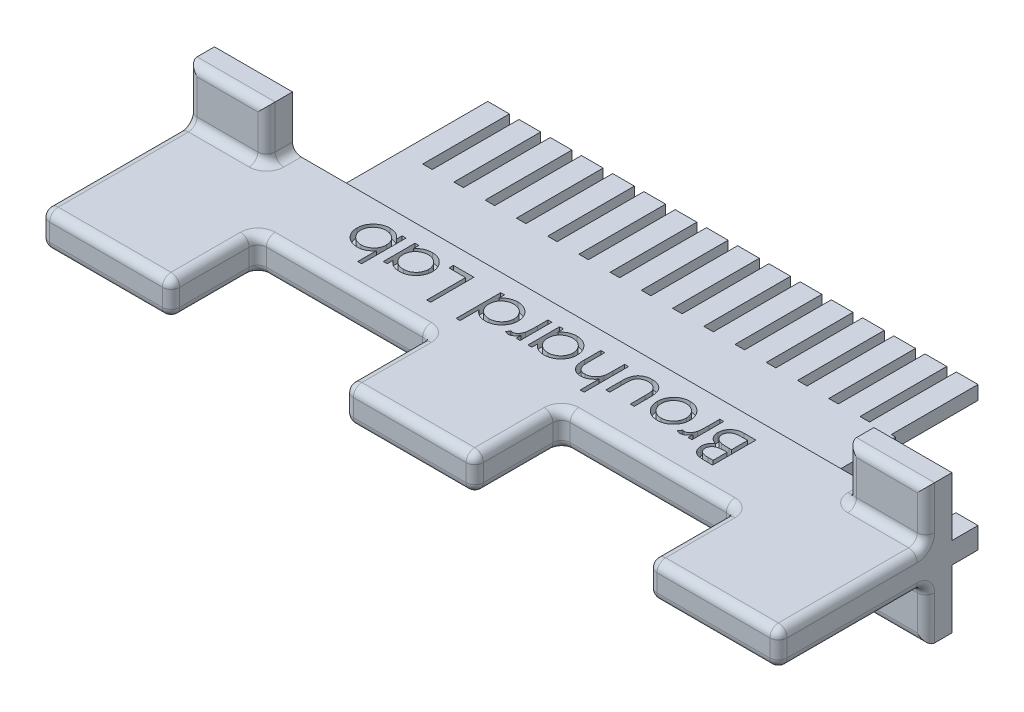
from build123d import *

# Parameters (mm, degrees)
SKETCH1_W           = 85
SKETCH1_H           = 4
BOSS_EXTRUDE1_DEPTH = 10
SKETCH2_W           = 15
SKETCH2_H           = 4
BOSS_EXTRUDE2_DEPTH = 10
SKETCH3_W           = 2.55
SKETCH3_H           = 2.45
BOSS_EXTRUDE3_DEPTH = 3
SKETCH4_W           = 57
SKETCH4_H           = 1.6
BOSS_EXTRUDE4_DEPTH = 7.5
SKETCH6_W           = 9
SKETCH6_H           = 6
BOSS_EXTRUDE6_DEPTH = 3
FILLET1_R           = 1
CUT_EXTRUDE1_DEPTH  = 1
SKETCH5_W           = 2.5
SKETCH5_H           = 1.6
BOSS_EXTRUDE5_DEPTH = 10


with BuildPart() as part:
    # Sketch1 → Boss-Extrude1 (new body)
    with BuildSketch(Plane.XY):
        Rectangle(SKETCH1_W, SKETCH1_H)
    extrude(amount=BOSS_EXTRUDE1_DEPTH)

    # Sketch2 → Boss-Extrude2 (add)
    with BuildSketch(Plane.XY.offset(10)):
        with Locations((-35, 0)):
            Rectangle(SKETCH2_W, SKETCH2_H)
        with Locations((35, 0)):
            Rectangle(SKETCH2_W, SKETCH2_H)
        Rectangle(SKETCH2_W, SKETCH2_H)
    extrude(amount=BOSS_EXTRUDE2_DEPTH)

    # Sketch3 → Boss-Extrude3 (add)
    with BuildSketch(Plane(origin=(0, 0, 0), x_dir=(-1, 0, 0), z_dir=(0, 0, -1))):
        with Locations((-41.225, 0)):
            Rectangle(SKETCH3_W, SKETCH3_H)
        with Locations((41.225, 0)):
            Rectangle(SKETCH3_W, SKETCH3_H)
    extrude(amount=BOSS_EXTRUDE3_DEPTH)

    # Sketch4 → Boss-Extrude4 (add)
    with BuildSketch(Plane(origin=(0, 0, 0), x_dir=(-1, 0, 0), z_dir=(0, 0, -1))):
        Rectangle(SKETCH4_W, SKETCH4_H)
    extrude(amount=BOSS_EXTRUDE4_DEPTH)

    # Sketch6 → Boss-Extrude6 (add)
    with BuildSketch(Plane(origin=(0, 0, 0), x_dir=(-1, 0, 0), z_dir=(0, 0, -1))):
        with Locations((38, -5)):
            Rectangle(SKETCH6_W, SKETCH6_H)
        with Locations((38, 5)):
            Rectangle(SKETCH6_W, SKETCH6_H)
        with Locations((-38, -5)):
            Rectangle(SKETCH6_W, SKETCH6_H)
        with Locations((-38, 5)):
            Rectangle(SKETCH6_W, SKETCH6_H)
    extrude(amount=-BOSS_EXTRUDE6_DEPTH)

    # Fillet1
    fillet1_edges = [part.edges().sort_by_distance(p)[0] for p in [
        (-42.5, 5, 3),
        (-38, 2, 3),
        (-33.5, 5, 3),
        (-33.5, 2, 1.5),
        (-38, 8, 3),
        (42.5, -5, 3),
        (38, -2, 3),
        (33.5, -5, 3),
        (33.5, -2, 1.5),
        (38, -8, 3),
        (42.5, 5, 3),
        (38, 8, 3),
        (33.5, 5, 3),
        (38, 2, 3),
        (33.5, 2, 1.5),
        (-17.5, -2, 10),
        (-27.5, 0, 10),
        (-27.5, -2, 15),
        (-27.5, 2, 15),
        (-42.5, 0, 20),
        (-35, -2, 20),
        (-27.5, 0, 20),
        (-35, 2, 20),
        (17.5, 2, 10),
        (27.5, 0, 10),
        (27.5, 2, 15),
        (27.5, -2, 15),
        (42.5, 0, 20),
        (35, 2, 20),
        (27.5, 0, 20),
        (35, -2, 20),
        (17.5, -2, 10),
        (-17.5, 2, 10),
        (7.5, 0, 10),
        (7.5, -2, 15),
        (7.5, 2, 15),
        (-7.5, 0, 10),
        (-7.5, 2, 15),
        (-7.5, -2, 15),
        (7.5, 0, 20),
        (0, 2, 20),
        (-7.5, 0, 20),
        (0, -2, 20),
        (42.5, -2, 11.5),
        (-42.5, -2, 11.5),
        (-42.5, 2, 11.5),
        (42.5, 2, 11.5),
        (-42.5, -5, 3),
        (-38, -8, 3),
        (-33.5, -5, 3),
        (-38, -2, 3),
        (-33.5, -2, 1.5),
    ]]
    fillet(fillet1_edges, radius=FILLET1_R)

    # Sketch8 → Cut-Extrude1 (cut)
    with BuildSketch(Plane(origin=(0, 2, 0), x_dir=(1, 0, 0), z_dir=(0, 1, 0))):
        with BuildLine():
            Line((21.955128205, -7.045024133), (20.979567308, -7.045024133))
            add(Edge.make_bspline(
                [(20.979567308, -7.045024133), (20.931811586, -7.044777014), (20.839249111, -7.044298035), (20.704660144, -7.036696988), (20.578554958, -7.026592114), (20.461156398, -7.009641733), (20.351700568, -6.992066423), (20.251298675, -6.966270076), (20.159109728, -6.937777071), (20.048409672, -6.893936716), (19.92280529, -6.825852091), (19.787804083, -6.724876123), (19.670452795, -6.603814091), (19.570669416, -6.465854357), (19.490591132, -6.314083016), (19.43339094, -6.151765477), (19.396643358, -5.981632539), (19.392911608, -5.864990679), (19.391025641, -5.806041761)],
                knots=[0, 0, 0, 0, 0.000143243, 0.000277641, 0.000404323, 0.000522601, 0.000633422, 0.000736665, 0.000833282, 0.000922745, 0.001093491, 0.001260157, 0.001426607, 0.001597303, 0.001769346, 0.001939468, 0.002112331, 0.002288957, 0.002288957, 0.002288957, 0.002288957], degree=3))
            add(Edge.make_bspline(
                [(19.391025641, -5.806041761), (19.392566125, -5.750816773), (19.395593321, -5.642294463), (19.425166581, -5.484100137), (19.4698067, -5.333038737), (19.534225102, -5.190566035), (19.616363978, -5.057933935), (19.716298264, -4.937404803), (19.834792937, -4.831345021), (19.923759393, -4.772321243), (19.968950321, -4.742339838)],
                knots=[0, 0, 0, 0, 0.00016551, 0.000325243, 0.000481139, 0.000637145, 0.000792791, 0.000947835, 0.001105294, 0.001267844, 0.001267844, 0.001267844, 0.001267844], degree=3))
            add(Edge.make_bspline(
                [(19.968950321, -4.742339838), (19.912145679, -4.720542475), (19.803464327, -4.678838718), (19.653711211, -4.604821394), (19.524645211, -4.524933301), (19.41460302, -4.438588883), (19.32239544, -4.34296875), (19.240253224, -4.240591123), (19.170541651, -4.127890536), (19.111062126, -4.007309158), (19.063944891, -3.879485542), (19.031238978, -3.745375962), (19.010496783, -3.606499394), (19.007784363, -3.512111636), (19.006410256, -3.464294967)],
                knots=[0, 0, 0, 0, 0.000182459, 0.00034909, 0.000500276, 0.000637148, 0.000767471, 0.00089793, 0.001030217, 0.001164151, 0.001300726, 0.001437979, 0.001577644, 0.001721044, 0.001721044, 0.001721044, 0.001721044], degree=3))
            add(Edge.make_bspline(
                [(19.006410256, -3.464294967), (19.007805885, -3.41548523), (19.010551822, -3.319450707), (19.030807012, -3.178370784), (19.065112767, -3.043553694), (19.112331393, -2.914102037), (19.173883248, -2.790773975), (19.248244287, -2.672600284), (19.337493216, -2.561332318), (19.437996289, -2.45535544), (19.550128803, -2.358444164), (19.673690061, -2.2751618), (19.805513315, -2.203227398), (19.947403728, -2.145396174), (20.098354491, -2.100124903), (20.258400966, -2.068824422), (20.427452272, -2.047649449), (20.543467886, -2.045914087), (20.602964744, -2.045024133)],
                knots=[0, 0, 0, 0, 0.000146402, 0.00028805, 0.000426518, 0.000563092, 0.000700608, 0.000839267, 0.000981145, 0.001127794, 0.001276955, 0.001424748, 0.00157399, 0.001726698, 0.001883553, 0.002046002, 0.002215459, 0.002393845, 0.002393845, 0.002393845, 0.002393845], degree=3))
            Line((20.602964744, -2.045024133), (21.955128205, -2.045024133))
            Line((21.955128205, -2.045024133), (21.955128205, -7.045024133))
        make_face()
        with BuildLine():
            Line((21.506410256, -6.53220362), (21.506410256, -4.929639518))
            Line((21.506410256, -4.929639518), (21.204927885, -4.929639518))
            add(Edge.make_bspline(
                [(21.204927885, -4.929639518), (21.16085778, -4.930206082), (21.075705357, -4.9313008), (20.952063514, -4.934535484), (20.837581625, -4.943196106), (20.731865233, -4.952356158), (20.635622811, -4.966460704), (20.548532434, -4.983720889), (20.469810894, -5.00181496), (20.379071632, -5.032675643), (20.276157749, -5.077807077), (20.16721677, -5.149562501), (20.069164992, -5.232639769), (19.988277934, -5.331182392), (19.920936523, -5.437599512), (19.875598165, -5.552684686), (19.843986577, -5.672472047), (19.841172407, -5.755083607), (19.83974359, -5.797027338)],
                knots=[0, 0, 0, 0, 0.000132227, 0.000255489, 0.000370952, 0.000476596, 0.000573767, 0.000662554, 0.000742964, 0.000815812, 0.000949851, 0.001078759, 0.001205868, 0.001333854, 0.001459773, 0.001581973, 0.001703679, 0.001829203, 0.001829203, 0.001829203, 0.001829203], degree=3))
            add(Edge.make_bspline(
                [(19.83974359, -5.797027338), (19.840440447, -5.824795004), (19.841807408, -5.879264312), (19.85469429, -5.958622966), (19.872478035, -6.034141042), (19.901807859, -6.103782707), (19.936556119, -6.169993364), (19.98109509, -6.230681546), (20.03245262, -6.287491301), (20.092329064, -6.338899898), (20.160479658, -6.385396007), (20.239063252, -6.424101797), (20.325943351, -6.458499162), (20.422931675, -6.48457317), (20.528096305, -6.507209559), (20.643041681, -6.521483941), (20.767075062, -6.530654029), (20.853013063, -6.531675569), (20.897435897, -6.53220362)],
                knots=[0, 0, 0, 0, 8.3229e-05, 0.000163264, 0.000240757, 0.000315341, 0.000389283, 0.000464617, 0.000540481, 0.000618594, 0.000700823, 0.000787274, 0.000880832, 0.000980716, 0.001088168, 0.001203335, 0.00132786, 0.001461107, 0.001461107, 0.001461107, 0.001461107], degree=3))
            Line((20.897435897, -6.53220362), (21.506410256, -6.53220362))
        make_face(mode=Mode.SUBTRACT)
        with BuildLine():
            Line((21.506410256, -4.416819005), (21.506410256, -2.557844646))
            Line((21.506410256, -2.557844646), (20.867387821, -2.557844646))
            add(Edge.make_bspline(
                [(20.867387821, -2.557844646), (20.82165107, -2.558445571), (20.733499514, -2.559603775), (20.606126985, -2.562352033), (20.48869926, -2.57254806), (20.380238634, -2.582323383), (20.281246941, -2.598293401), (20.190761319, -2.61375789), (20.110848501, -2.63651465), (20.017345889, -2.667828353), (19.912764158, -2.717871803), (19.798555972, -2.791464981), (19.697962318, -2.881106895), (19.612615651, -2.984324471), (19.541653639, -3.095395221), (19.492561941, -3.214537751), (19.460753316, -3.337772506), (19.457007017, -3.422035912), (19.455128205, -3.464294967)],
                knots=[0, 0, 0, 0, 0.000137234, 0.000264501, 0.000382034, 0.000490767, 0.000591058, 0.000682796, 0.000765899, 0.000840017, 0.000978463, 0.001112367, 0.001246451, 0.001380849, 0.001513136, 0.001640186, 0.001766022, 0.001892621, 0.001892621, 0.001892621, 0.001892621], degree=3))
            add(Edge.make_bspline(
                [(19.455128205, -3.464294967), (19.455511728, -3.490717987), (19.456272588, -3.543137822), (19.468232548, -3.620102651), (19.484829912, -3.695025725), (19.509289766, -3.766889341), (19.538879538, -3.836930979), (19.577915987, -3.902871611), (19.621948812, -3.967518228), (19.690148998, -4.050208407), (19.790699472, -4.144331407), (19.933635519, -4.235332182), (20.095250073, -4.309910154), (20.212743455, -4.341437989), (20.2734375, -4.357724454)],
                knots=[0, 0, 0, 0, 7.9184e-05, 0.00015709, 0.000233139, 0.000309156, 0.000384516, 0.000460796, 0.000538586, 0.000618995, 0.000781989, 0.000949233, 0.001125381, 0.001313608, 0.001313608, 0.001313608, 0.001313608], degree=3))
            add(Edge.make_bspline(
                [(20.2734375, -4.357724454), (20.297764757, -4.36266062), (20.350511268, -4.373363246), (20.436522534, -4.384653585), (20.535045896, -4.394781387), (20.645660247, -4.402076233), (20.768805516, -4.409907124), (20.904442139, -4.412844185), (21.052666008, -4.416429024), (21.15551238, -4.416685686), (21.208934295, -4.416819005)],
                knots=[0, 0, 0, 0, 7.4449e-05, 0.000161422, 0.000260089, 0.000371555, 0.000493951, 0.000630228, 0.000778496, 0.000938755, 0.000938755, 0.000938755, 0.000938755], degree=3))
            Line((21.208934295, -4.416819005), (21.506410256, -4.416819005))
        make_face(mode=Mode.SUBTRACT)
        with BuildLine():
            Line((18.237179487, -5.698870287), (17.788461538, -5.698870287))
            Line((17.788461538, -5.698870287), (17.788461538, -5.16100971))
            add(Edge.make_bspline(
                [(17.788461538, -5.16100971), (17.755359908, -5.211117117), (17.692053298, -5.306947144), (17.586273377, -5.43343718), (17.479111393, -5.53983342), (17.366921794, -5.622588498), (17.252557594, -5.685650706), (17.136357118, -5.730343447), (17.017481778, -5.757585182), (16.937237879, -5.761174556), (16.897035256, -5.762972851)],
                knots=[0, 0, 0, 0, 0.000180032, 0.00034431, 0.000493764, 0.000631989, 0.000761087, 0.000884414, 0.00100446, 0.00112499, 0.00112499, 0.00112499, 0.00112499], degree=3))
            add(Edge.make_bspline(
                [(16.897035256, -5.762972851), (16.865844687, -5.761310147), (16.801992924, -5.757906343), (16.705041331, -5.732794344), (16.604739598, -5.694222955), (16.540012887, -5.657063647), (16.506410256, -5.637772531)],
                knots=[0, 0, 0, 0, 9.3493e-05, 0.000191394, 0.000298902, 0.000414971, 0.000414971, 0.000414971, 0.000414971], degree=3))
            Line((16.506410256, -5.637772531), (16.752804487, -5.249150736))
            add(Edge.make_bspline(
                [(16.752804487, -5.249150736), (16.774388803, -5.258779687), (16.815359967, -5.277057281), (16.875295061, -5.298688724), (16.930554114, -5.311425747), (16.965759197, -5.313355343), (16.982171474, -5.314254902)],
                knots=[0, 0, 0, 0, 7.0888e-05, 0.000134558, 0.000190943, 0.000240184, 0.000240184, 0.000240184, 0.000240184], degree=3))
            add(Edge.make_bspline(
                [(16.982171474, -5.314254902), (17.018552318, -5.311962095), (17.092095887, -5.307327204), (17.199553418, -5.267726819), (17.305221395, -5.20820996), (17.387285817, -5.138004944), (17.451536641, -5.071852679), (17.497773588, -5.013639038), (17.539299542, -4.947803919), (17.579572406, -4.876841023), (17.616991286, -4.798984205), (17.65042989, -4.714102186), (17.681701622, -4.622897124), (17.699312387, -4.559480067), (17.708333333, -4.526995287)],
                knots=[0, 0, 0, 0, 0.000108839, 0.000220017, 0.000339778, 0.000471355, 0.000542193, 0.000616339, 0.000693851, 0.000775474, 0.000861039, 0.000952734, 0.001049023, 0.001150145, 0.001150145, 0.001150145, 0.001150145], degree=3))
            add(Edge.make_bspline(
                [(17.708333333, -4.526995287), (17.715105579, -4.4980295), (17.73018081, -4.433550753), (17.744447085, -4.325868753), (17.75911049, -4.198727857), (17.769124119, -4.051980366), (17.778583328, -3.885062178), (17.783808984, -3.698693379), (17.788295276, -3.492361731), (17.78840435, -3.348446216), (17.788461538, -3.272988877)],
                knots=[0, 0, 0, 0, 8.9193e-05, 0.000198547, 0.000325526, 0.000473173, 0.000639683, 0.000827079, 0.001032447, 0.001258811, 0.001258811, 0.001258811, 0.001258811], degree=3))
            Line((17.788461538, -3.272988877), (17.788461538, -2.045024133))
            Line((17.788461538, -2.045024133), (18.237179487, -2.045024133))
            Line((18.237179487, -2.045024133), (18.237179487, -5.698870287))
        make_face()
        with BuildLine():
            add(Edge.make_bspline(
                [(14.29286859, -5.762972851), (14.224307927, -5.761517291), (14.089877222, -5.758663293), (13.893032913, -5.728009819), (13.705327588, -5.681525783), (13.525956048, -5.616093456), (13.356402056, -5.530243686), (13.195151776, -5.426425769), (13.042528278, -5.303937317), (12.951070622, -5.209132095), (12.904647436, -5.16100971)],
                knots=[0, 0, 0, 0, 0.000205526, 0.000402987, 0.000596112, 0.000784972, 0.000974447, 0.001165038, 0.001359476, 0.001559909, 0.001559909, 0.001559909, 0.001559909], degree=3))
            add(Edge.make_bspline(
                [(12.904647436, -5.16100971), (12.864673216, -5.11498973), (12.785498387, -5.023840384), (12.683975931, -4.876046652), (12.59651656, -4.722989365), (12.526426616, -4.562636041), (12.471162296, -4.396386511), (12.431925587, -4.223669352), (12.408587109, -4.044865999), (12.405440013, -3.923431945), (12.403846154, -3.861931185)],
                knots=[0, 0, 0, 0, 0.000182745, 0.000361954, 0.000536876, 0.000710881, 0.000886036, 0.001061708, 0.001241475, 0.001425944, 0.001425944, 0.001425944, 0.001425944], degree=3))
            add(Edge.make_bspline(
                [(12.403846154, -3.861931185), (12.405248064, -3.800073959), (12.408018305, -3.677841197), (12.434223472, -3.497813533), (12.474982163, -3.323249495), (12.533313369, -3.154879952), (12.608110636, -2.992190127), (12.699383171, -2.835891045), (12.807770716, -2.685672654), (12.930635425, -2.542816985), (13.066416897, -2.411135675), (13.21375075, -2.296436369), (13.369848434, -2.197755629), (13.536840837, -2.119375683), (13.712350874, -2.056195988), (13.8974949, -2.012629522), (14.09210775, -1.986052796), (14.225006973, -1.982656037), (14.29286859, -1.980921569)],
                knots=[0, 0, 0, 0, 0.00018547, 0.000366497, 0.000544574, 0.000722589, 0.000900065, 0.001080956, 0.001264689, 0.001455025, 0.001645575, 0.001831106, 0.002014249, 0.002198383, 0.002383395, 0.002572886, 0.002767942, 0.002971467, 0.002971467, 0.002971467, 0.002971467], degree=3))
            add(Edge.make_bspline(
                [(14.29286859, -1.980921569), (14.361059424, -1.982670388), (14.494614618, -1.986095539), (14.689960267, -2.012431829), (14.875883807, -2.056661478), (15.052224048, -2.118593533), (15.219215773, -2.198399418), (15.37588985, -2.296052412), (15.523293198, -2.411193757), (15.65911724, -2.542801247), (15.781970535, -2.685676709), (15.890361026, -2.835889993), (15.981632796, -2.992190401), (16.056430263, -3.154879879), (16.114761415, -3.323249515), (16.155520121, -3.497813528), (16.181725284, -3.677841198), (16.184495525, -3.80007396), (16.185897436, -3.861931185)],
                knots=[0, 0, 0, 0, 0.000204526, 0.000400574, 0.000590065, 0.000776965, 0.000960195, 0.001144188, 0.00132972, 0.001520269, 0.001710605, 0.001894339, 0.00207523, 0.002252706, 0.002430721, 0.002608798, 0.002789825, 0.002975294, 0.002975294, 0.002975294, 0.002975294], degree=3))
            add(Edge.make_bspline(
                [(16.185897436, -3.861931185), (16.184296519, -3.923099043), (16.18112698, -4.044200892), (16.157756652, -4.22264832), (16.118946868, -4.394836864), (16.062916427, -4.560178538), (15.992956591, -4.720146456), (15.90637746, -4.873764934), (15.803872945, -5.02091287), (15.725005709, -5.111941341), (15.685096154, -5.158004902)],
                knots=[0, 0, 0, 0, 0.000183468, 0.000363236, 0.000538908, 0.000712162, 0.000886167, 0.001061962, 0.001240348, 0.001423094, 0.001423094, 0.001423094, 0.001423094], degree=3))
            add(Edge.make_bspline(
                [(15.685096154, -5.158004902), (15.638739114, -5.20653651), (15.547569839, -5.301982456), (15.394241809, -5.424229232), (15.233685171, -5.529446865), (15.063037498, -5.615253429), (14.883167202, -5.681407061), (14.694066814, -5.728226774), (14.496506031, -5.758527704), (14.361424213, -5.761476369), (14.29286859, -5.762972851)],
                knots=[0, 0, 0, 0, 0.00020114, 0.000395577, 0.000586713, 0.000776188, 0.000967274, 0.001160399, 0.001359841, 0.001565367, 0.001565367, 0.001565367, 0.001565367], degree=3))
        make_face()
        with BuildLine():
            add(Edge.make_bspline(
                [(14.294871795, -5.314254902), (14.343354042, -5.31287684), (14.439066976, -5.310156289), (14.579952881, -5.289466071), (14.715578773, -5.256679949), (14.84621924, -5.210117374), (14.971369132, -5.149920796), (15.091165691, -5.076401027), (15.205288814, -4.989167289), (15.312855022, -4.88995037), (15.412753003, -4.782192755), (15.499001382, -4.666286529), (15.572889716, -4.545452386), (15.633262525, -4.419007361), (15.679580189, -4.286604065), (15.712397714, -4.149000046), (15.733127199, -4.005785755), (15.735814091, -3.908409845), (15.737179487, -3.858926377)],
                knots=[0, 0, 0, 0, 0.000145402, 0.00028705, 0.000426247, 0.000563423, 0.000702299, 0.000842129, 0.000984361, 0.00113252, 0.001280679, 0.00142451, 0.001565195, 0.001704975, 0.001844039, 0.001985183, 0.002128814, 0.002277217, 0.002277217, 0.002277217, 0.002277217], degree=3))
            add(Edge.make_bspline(
                [(15.737179487, -3.858926377), (15.734890082, -3.794992084), (15.730346041, -3.668094469), (15.693206633, -3.48126298), (15.631516344, -3.301562306), (15.546449569, -3.131156088), (15.441687276, -2.973216762), (15.31918926, -2.831196974), (15.177261944, -2.710573578), (15.020738225, -2.609127271), (14.851836243, -2.5292384), (14.673387712, -2.471947456), (14.487017459, -2.435206285), (14.359480893, -2.431511347), (14.294871795, -2.429639518)],
                knots=[0, 0, 0, 0, 0.000191683, 0.000380455, 0.000568919, 0.000760186, 0.000950198, 0.001136194, 0.00132088, 0.001507019, 0.001694298, 0.001879594, 0.002068178, 0.002261801, 0.002261801, 0.002261801, 0.002261801], degree=3))
            add(Edge.make_bspline(
                [(14.294871795, -2.429639518), (14.23025898, -2.431500504), (14.102715078, -2.435174039), (13.916085515, -2.472133599), (13.737147914, -2.528989279), (13.568070317, -2.609217501), (13.411475317, -2.710190138), (13.270561459, -2.831884154), (13.147008507, -2.972843418), (13.04214248, -3.130946672), (12.958446366, -3.301827223), (12.896465966, -3.481229869), (12.859415628, -3.668102902), (12.854859565, -3.794994909), (12.852564103, -3.858926377)],
                knots=[0, 0, 0, 0, 0.000193623, 0.000382206, 0.000568456, 0.000755734, 0.000941873, 0.001125801, 0.001312456, 0.001502468, 0.001693291, 0.001881755, 0.002070527, 0.00226221, 0.00226221, 0.00226221, 0.00226221], degree=3))
            add(Edge.make_bspline(
                [(12.852564103, -3.858926377), (12.85391927, -3.908413822), (12.856586033, -4.00579756), (12.877461924, -4.148954918), (12.909764333, -4.286878115), (12.958078967, -4.418473367), (13.016348399, -4.546067931), (13.092028067, -4.665924648), (13.177874936, -4.782266279), (13.277956043, -4.889885455), (13.385510177, -4.98952979), (13.500490643, -5.076083255), (13.620342842, -5.149962779), (13.745532283, -5.210124787), (13.875877117, -5.256500729), (14.011091241, -5.289608892), (14.151353237, -5.310080851), (14.246726302, -5.312854653), (14.294871795, -5.314254902)],
                knots=[0, 0, 0, 0, 0.000148403, 0.000292034, 0.000433178, 0.000572578, 0.00071193, 0.000853138, 0.000996969, 0.001145128, 0.001293287, 0.001436317, 0.001576147, 0.001715023, 0.001852199, 0.001990424, 0.002132072, 0.002276473, 0.002276473, 0.002276473, 0.002276473], degree=3))
        make_face(mode=Mode.SUBTRACT)
        with BuildLine():
            Line((11.570512821, -5.698870287), (11.121794872, -5.698870287))
            Line((11.121794872, -5.698870287), (11.121794872, -4.004158749))
            add(Edge.make_bspline(
                [(11.121794872, -4.004158749), (11.121592151, -3.954411964), (11.121204354, -3.859248695), (11.118574439, -3.722312714), (11.112388591, -3.597431696), (11.104654555, -3.484533501), (11.094708647, -3.383637227), (11.082875275, -3.295095289), (11.069648958, -3.217903597), (11.056702224, -3.171413089), (11.05068109, -3.149791761)],
                knots=[0, 0, 0, 0, 0.000149242, 0.000285493, 0.000410838, 0.000524302, 0.000624962, 0.000714911, 0.000792314, 0.000859608, 0.000859608, 0.000859608, 0.000859608], degree=3))
            add(Edge.make_bspline(
                [(11.05068109, -3.149791761), (11.041021805, -3.122616307), (11.02190405, -3.06883037), (10.987228565, -2.991130691), (10.944327515, -2.919170094), (10.897397624, -2.850149082), (10.843207537, -2.786203671), (10.78254961, -2.72691621), (10.716500508, -2.671595092), (10.619751651, -2.6048734), (10.487494763, -2.534263345), (10.314242396, -2.472488378), (10.126045943, -2.436112097), (9.995820794, -2.431836921), (9.928886218, -2.429639518)],
                knots=[0, 0, 0, 0, 8.6516e-05, 0.000171232, 0.000254721, 0.000337515, 0.000421387, 0.00050567, 0.000591721, 0.00067952, 0.000857864, 0.001039709, 0.001229465, 0.001430146, 0.001430146, 0.001430146, 0.001430146], degree=3))
            add(Edge.make_bspline(
                [(9.928886218, -2.429639518), (9.86194316, -2.431828713), (9.732748927, -2.436053669), (9.546518851, -2.471939165), (9.375968682, -2.530483395), (9.223089747, -2.613350563), (9.088841758, -2.714376404), (8.976981124, -2.832969142), (8.884684323, -2.965323174), (8.844385248, -3.064072442), (8.82411859, -3.113734069)],
                knots=[0, 0, 0, 0, 0.000200681, 0.000387296, 0.000566586, 0.000739571, 0.000906841, 0.001068376, 0.001227003, 0.001387484, 0.001387484, 0.001387484, 0.001387484], degree=3))
            add(Edge.make_bspline(
                [(8.82411859, -3.113734069), (8.8181224, -3.1336855), (8.80486629, -3.177793242), (8.790725551, -3.252630176), (8.777460105, -3.341789135), (8.768616165, -3.446206446), (8.758522511, -3.564961319), (8.755037146, -3.698667884), (8.750059864, -3.846538026), (8.750020544, -3.950065981), (8.75, -4.004158749)],
                knots=[0, 0, 0, 0, 6.2462e-05, 0.000138088, 0.000228176, 0.000332823, 0.000452355, 0.000585662, 0.000733953, 0.000896216, 0.000896216, 0.000896216, 0.000896216], degree=3))
            Line((8.75, -4.004158749), (8.75, -5.698870287))
            Line((8.75, -5.698870287), (8.301282051, -5.698870287))
            Line((8.301282051, -5.698870287), (8.301282051, -3.920024133))
            add(Edge.make_bspline(
                [(8.301282051, -3.920024133), (8.30191531, -3.859585653), (8.303143917, -3.742326733), (8.310980731, -3.571916291), (8.324614367, -3.412799073), (8.344773775, -3.265462167), (8.369229918, -3.129870336), (8.400154934, -3.00598092), (8.437277048, -2.893621613), (8.479165629, -2.791153018), (8.528529202, -2.698158121), (8.581390514, -2.610389295), (8.640827886, -2.528135886), (8.705652894, -2.450645369), (8.777741804, -2.379798189), (8.85333008, -2.311961845), (8.93610888, -2.251321381), (9.023288539, -2.194646502), (9.117066908, -2.144351467), (9.216637391, -2.100832577), (9.321894658, -2.063022013), (9.433003103, -2.033803946), (9.549897573, -2.009153726), (9.67242881, -1.992746928), (9.800829998, -1.982271357), (9.888132562, -1.981379054), (9.932892628, -1.980921569)],
                knots=[0, 0, 0, 0, 0.000181315, 0.000351776, 0.000511647, 0.000660239, 0.000797754, 0.000924804, 0.001042946, 0.001152506, 0.001256441, 0.001358477, 0.001459659, 0.001560587, 0.001661157, 0.001762636, 0.001865001, 0.001968632, 0.00207439, 0.002183817, 0.002294379, 0.002409546, 0.002528193, 0.002652561, 0.002780158, 0.002914407, 0.002914407, 0.002914407, 0.002914407], degree=3))
            add(Edge.make_bspline(
                [(9.932892628, -1.980921569), (9.977316456, -1.981406186), (10.064613414, -1.982358504), (10.192711845, -1.992570693), (10.315507575, -2.00940504), (10.432494069, -2.033606354), (10.544142851, -2.063257518), (10.649911875, -2.100566743), (10.749934706, -2.144600485), (10.84442655, -2.194693497), (10.933073912, -2.251115088), (11.015677547, -2.313213364), (11.093710062, -2.379368112), (11.165005381, -2.451835522), (11.23008642, -2.530073038), (11.28923533, -2.613729086), (11.343463789, -2.701858176), (11.392537938, -2.79623559), (11.434697953, -2.899909467), (11.471919623, -3.014619732), (11.502363426, -3.141623289), (11.527138371, -3.28081177), (11.547069003, -3.431518969), (11.560906348, -3.594616706), (11.568643249, -3.769707694), (11.569876194, -3.890636109), (11.570512821, -3.953077018)],
                knots=[0, 0, 0, 0, 0.000133247, 0.000261843, 0.000385219, 0.000504847, 0.000620013, 0.00073152, 0.000840947, 0.000947589, 0.001052063, 0.001155829, 0.001257407, 0.001358687, 0.001460383, 0.00156238, 0.001665793, 0.001770617, 0.001881102, 0.002001148, 0.002132087, 0.002272558, 0.00242512, 0.002587985, 0.002763448, 0.002950772, 0.002950772, 0.002950772, 0.002950772], degree=3))
            Line((11.570512821, -3.953077018), (11.570512821, -5.698870287))
        make_face()
        with BuildLine():
            Line((7.275641026, -7.173229261), (6.826923077, -7.173229261))
            Line((6.826923077, -7.173229261), (6.826923077, -5.00876612))
            add(Edge.make_bspline(
                [(6.826923077, -5.00876612), (6.778678808, -5.068888094), (6.684893793, -5.185762911), (6.528113976, -5.339904506), (6.36474826, -5.471196487), (6.193410264, -5.578408978), (6.014828183, -5.661579829), (5.828563194, -5.719766634), (5.635090167, -5.756050633), (5.503296595, -5.760649137), (5.436698718, -5.762972851)],
                knots=[0, 0, 0, 0, 0.000231093, 0.000449235, 0.000658061, 0.000858722, 0.001054107, 0.001247341, 0.001442817, 0.001642498, 0.001642498, 0.001642498, 0.001642498], degree=3))
            add(Edge.make_bspline(
                [(5.436698718, -5.762972851), (5.369051259, -5.760620551), (5.236582495, -5.756014225), (5.044402774, -5.715426657), (4.863656734, -5.651196128), (4.696758785, -5.560924861), (4.546286047, -5.448841659), (4.415775284, -5.31738737), (4.306291209, -5.168293369), (4.233038251, -5.029320354), (4.185028125, -4.905733149), (4.154679673, -4.799671692), (4.128934509, -4.68150037), (4.106507375, -4.551264166), (4.091559078, -4.408342759), (4.079552578, -4.253379458), (4.071014758, -4.086383599), (4.070683898, -3.970783239), (4.070512821, -3.91100971)],
                knots=[0, 0, 0, 0, 0.000202742, 0.000397014, 0.000586474, 0.000776485, 0.000963986, 0.001147421, 0.001330122, 0.001516953, 0.001616837, 0.001727454, 0.0018475, 0.00197956, 0.002123683, 0.002278397, 0.002445857, 0.002625155, 0.002625155, 0.002625155, 0.002625155], degree=3))
            Line((4.070512821, -3.91100971), (4.070512821, -2.045024133))
            Line((4.070512821, -2.045024133), (4.519230769, -2.045024133))
            Line((4.519230769, -2.045024133), (4.519230769, -3.763774133))
            add(Edge.make_bspline(
                [(4.519230769, -3.763774133), (4.519501544, -3.813520868), (4.52001949, -3.908677905), (4.521752659, -4.044914373), (4.525533642, -4.16814974), (4.531869413, -4.278639822), (4.53824468, -4.376234881), (4.547283145, -4.46109433), (4.557720701, -4.532685817), (4.567105279, -4.575778103), (4.571314103, -4.595104261)],
                knots=[0, 0, 0, 0, 0.000149242, 0.000285475, 0.000408737, 0.000519077, 0.000617484, 0.0007021, 0.000775053, 0.000834376, 0.000834376, 0.000834376, 0.000834376], degree=3))
            add(Edge.make_bspline(
                [(4.571314103, -4.595104261), (4.587558684, -4.651851981), (4.618706291, -4.760660919), (4.692549434, -4.908198617), (4.782632802, -5.035130852), (4.894290172, -5.137852366), (5.023812243, -5.21879062), (5.172428658, -5.273933897), (5.338240367, -5.309099366), (5.454866892, -5.312485195), (5.515825321, -5.314254902)],
                knots=[0, 0, 0, 0, 0.000176748, 0.000338899, 0.000492364, 0.000641202, 0.000791008, 0.00094763, 0.001114405, 0.001297029, 0.001297029, 0.001297029, 0.001297029], degree=3))
            add(Edge.make_bspline(
                [(5.515825321, -5.314254902), (5.551925349, -5.313584935), (5.623366372, -5.312259087), (5.729246241, -5.298610846), (5.8322736, -5.277055291), (5.932171925, -5.245215815), (6.029144995, -5.206505033), (6.123586995, -5.15899916), (6.21420543, -5.101559446), (6.302169918, -5.036911618), (6.384056208, -4.965394032), (6.460236741, -4.889895628), (6.528148933, -4.809503542), (6.589675418, -4.725503187), (6.642787274, -4.636743532), (6.689148815, -4.544080206), (6.728485525, -4.44739143), (6.748032228, -4.380284199), (6.7578125, -4.346706826)],
                knots=[0, 0, 0, 0, 0.000108247, 0.000214218, 0.000319711, 0.000423617, 0.000528331, 0.0006327, 0.00074025, 0.000849828, 0.000959881, 0.001066117, 0.001171281, 0.001275259, 0.001378152, 0.001481176, 0.00158589, 0.001690753, 0.001690753, 0.001690753, 0.001690753], degree=3))
            add(Edge.make_bspline(
                [(6.7578125, -4.346706826), (6.763440253, -4.322391181), (6.77570382, -4.2694044), (6.789010725, -4.182012509), (6.800921863, -4.080460549), (6.81099122, -3.964902548), (6.817167057, -3.834915059), (6.823821687, -3.691385118), (6.82629885, -3.533413659), (6.826708783, -3.423562934), (6.826923077, -3.366137915)],
                knots=[0, 0, 0, 0, 7.4853e-05, 0.000163113, 0.000264986, 0.000381603, 0.000511, 0.000655356, 0.000812636, 0.000984915, 0.000984915, 0.000984915, 0.000984915], degree=3))
            Line((6.826923077, -3.366137915), (6.826923077, -2.045024133))
            Line((6.826923077, -2.045024133), (7.275641026, -2.045024133))
            Line((7.275641026, -2.045024133), (7.275641026, -7.173229261))
        make_face()
        with BuildLine():
            Line((-0.673076923, -5.698870287), (-0.673076923, -2.045024133))
            Line((-0.673076923, -2.045024133), (-0.224358974, -2.045024133))
            Line((-0.224358974, -2.045024133), (-0.224358974, -2.677035351))
            add(Edge.make_bspline(
                [(-0.224358974, -2.677035351), (-0.173692153, -2.619914798), (-0.074668173, -2.508277549), (0.089136249, -2.361533046), (0.264203306, -2.241723382), (0.447550404, -2.144473643), (0.640596711, -2.07116495), (0.842208477, -2.019519884), (1.052227954, -1.985924035), (1.195449856, -1.982604018), (1.268028846, -1.980921569)],
                knots=[0, 0, 0, 0, 0.000228947, 0.000447457, 0.00065777, 0.000863866, 0.001068669, 0.001275649, 0.001487424, 0.001705002, 0.001705002, 0.001705002, 0.001705002], degree=3))
            add(Edge.make_bspline(
                [(1.268028846, -1.980921569), (1.33255467, -1.982673239), (1.459802451, -1.986127609), (1.646984326, -2.01293508), (1.827125421, -2.055963389), (2.000340544, -2.115878617), (2.16545602, -2.194944018), (2.323402232, -2.290624075), (2.474547798, -2.403447762), (2.616018245, -2.532931528), (2.746457503, -2.673420564), (2.860578679, -2.823701191), (2.957300092, -2.98170931), (3.03678777, -3.14740051), (3.098299504, -3.320653672), (3.141095026, -3.50134994), (3.16787361, -3.689188645), (3.17132623, -3.817102795), (3.173076923, -3.881963236)],
                knots=[0, 0, 0, 0, 0.000193519, 0.000381629, 0.000566016, 0.000748473, 0.000930368, 0.001114167, 0.001301667, 0.001495236, 0.001688742, 0.001876044, 0.002060364, 0.002243594, 0.002426383, 0.002610771, 0.002799872, 0.002994392, 0.002994392, 0.002994392, 0.002994392], degree=3))
            add(Edge.make_bspline(
                [(3.173076923, -3.881963236), (3.1712874, -3.945483083), (3.167749609, -4.071058395), (3.141381566, -4.255738336), (3.097074815, -4.43363601), (3.034777431, -4.604092418), (2.955247483, -4.767794043), (2.856862681, -4.923460082), (2.742782629, -5.073471787), (2.610949305, -5.213018547), (2.468209109, -5.341451795), (2.316217898, -5.454549666), (2.156870853, -5.549984408), (1.989848458, -5.627563574), (1.81633338, -5.689212702), (1.635007518, -5.732188081), (1.446695469, -5.757450724), (1.318853253, -5.761114455), (1.25400641, -5.762972851)],
                knots=[0, 0, 0, 0, 0.000190518, 0.000376644, 0.000558351, 0.000739594, 0.000920119, 0.001103261, 0.001291171, 0.001484625, 0.001678266, 0.00186657, 0.002052086, 0.00223446, 0.002418194, 0.002603555, 0.002792521, 0.002987041, 0.002987041, 0.002987041, 0.002987041], degree=3))
            add(Edge.make_bspline(
                [(1.25400641, -5.762972851), (1.179433695, -5.760926632), (1.03320012, -5.756914093), (0.81900525, -5.723236763), (0.616281151, -5.666868078), (0.423271915, -5.589930632), (0.242689948, -5.486323272), (0.072799241, -5.358126181), (-0.084384391, -5.202231444), (-0.176893656, -5.083637559), (-0.224358974, -5.022788556)],
                knots=[0, 0, 0, 0, 0.000223629, 0.000438526, 0.00064848, 0.000853819, 0.001060171, 0.00127111, 0.001490669, 0.00172203, 0.00172203, 0.00172203, 0.00172203], degree=3))
            Line((-0.224358974, -5.022788556), (-0.224358974, -5.698870287))
            Line((-0.224358974, -5.698870287), (-0.673076923, -5.698870287))
        make_face()
        with BuildLine():
            add(Edge.make_bspline(
                [(1.247996795, -5.314254902), (1.313587334, -5.311919162), (1.443052626, -5.307308782), (1.633135329, -5.271375167), (1.81493707, -5.211432861), (1.988162207, -5.129927244), (2.148028307, -5.025521063), (2.293274093, -4.90241808), (2.4199622, -4.759110049), (2.527080559, -4.598889493), (2.61600865, -4.428155027), (2.677375939, -4.248376808), (2.71813637, -4.064413876), (2.722279372, -3.93960414), (2.724358974, -3.876955223)],
                knots=[0, 0, 0, 0, 0.000196682, 0.000388218, 0.000577945, 0.000769701, 0.000960837, 0.001149109, 0.001339255, 0.001532603, 0.001726118, 0.001914908, 0.002101131, 0.002288816, 0.002288816, 0.002288816, 0.002288816], degree=3))
            add(Edge.make_bspline(
                [(2.724358974, -3.876955223), (2.721659394, -3.814696014), (2.716270816, -3.690421632), (2.678628159, -3.506176784), (2.612554386, -3.327571475), (2.52557156, -3.154636161), (2.41676702, -2.993220534), (2.290328958, -2.847266396), (2.144346166, -2.722265786), (1.983072348, -2.617564507), (1.811006067, -2.533340742), (1.629993631, -2.473937453), (1.443190032, -2.436430737), (1.315946515, -2.431910872), (1.252003205, -2.429639518)],
                knots=[0, 0, 0, 0, 0.000186753, 0.000372773, 0.00056129, 0.00075659, 0.000952159, 0.001143808, 0.001334144, 0.001526666, 0.001719289, 0.001907113, 0.002096868, 0.002288551, 0.002288551, 0.002288551, 0.002288551], degree=3))
            add(Edge.make_bspline(
                [(1.252003205, -2.429639518), (1.187080663, -2.432002624), (1.058284568, -2.436690656), (0.867544613, -2.472872088), (0.682784064, -2.533558691), (0.505507589, -2.61619592), (0.340640106, -2.718645983), (0.193357608, -2.839118095), (0.066119696, -2.97708118), (-0.038639755, -3.131710873), (-0.122341141, -3.29936144), (-0.181608072, -3.478428524), (-0.217604718, -3.667848043), (-0.222076425, -3.797668511), (-0.224358974, -3.86393439)],
                knots=[0, 0, 0, 0, 0.000194682, 0.000386219, 0.000580065, 0.000776779, 0.000971601, 0.00116089, 0.001345905, 0.001532593, 0.001719381, 0.001906254, 0.002096806, 0.002295487, 0.002295487, 0.002295487, 0.002295487], degree=3))
            add(Edge.make_bspline(
                [(-0.224358974, -3.86393439), (-0.222988015, -3.914416985), (-0.220289533, -4.013782709), (-0.199674743, -4.159679441), (-0.166880858, -4.29929803), (-0.120676169, -4.432791295), (-0.059958997, -4.559398956), (0.013194296, -4.680113441), (0.100284193, -4.793810311), (0.198660327, -4.90034558), (0.307556085, -4.997030357), (0.42335261, -5.082247508), (0.545758559, -5.154364667), (0.674688011, -5.212077257), (0.809147942, -5.259094257), (0.950427125, -5.290148173), (1.097101723, -5.311539529), (1.197168848, -5.313340248), (1.247996795, -5.314254902)],
                knots=[0, 0, 0, 0, 0.000151404, 0.000298012, 0.000441104, 0.000581114, 0.000720894, 0.000861579, 0.00100381, 0.001149818, 0.001295962, 0.001440002, 0.001580519, 0.001721272, 0.001863175, 0.002007015, 0.002154615, 0.002306977, 0.002306977, 0.002306977, 0.002306977], degree=3))
        make_face(mode=Mode.SUBTRACT)
        with BuildLine():
            Line((-1.570512821, -5.698870287), (-2.019230769, -5.698870287))
            Line((-2.019230769, -5.698870287), (-2.019230769, -5.16100971))
            add(Edge.make_bspline(
                [(-2.019230769, -5.16100971), (-2.052332399, -5.211117117), (-2.11563901, -5.306947144), (-2.221418931, -5.43343718), (-2.328580915, -5.53983342), (-2.440770514, -5.622588498), (-2.555134714, -5.685650706), (-2.67133519, -5.730343447), (-2.79021053, -5.757585182), (-2.870454429, -5.761174556), (-2.910657051, -5.762972851)],
                knots=[0, 0, 0, 0, 0.000180032, 0.00034431, 0.000493764, 0.000631989, 0.000761087, 0.000884414, 0.00100446, 0.00112499, 0.00112499, 0.00112499, 0.00112499], degree=3))
            add(Edge.make_bspline(
                [(-2.910657051, -5.762972851), (-2.94184762, -5.761310147), (-3.005699384, -5.757906343), (-3.102650976, -5.732794344), (-3.202952709, -5.694222955), (-3.267679421, -5.657063647), (-3.301282051, -5.637772531)],
                knots=[0, 0, 0, 0, 9.3493e-05, 0.000191394, 0.000298902, 0.000414971, 0.000414971, 0.000414971, 0.000414971], degree=3))
            Line((-3.301282051, -5.637772531), (-3.054887821, -5.249150736))
            add(Edge.make_bspline(
                [(-3.054887821, -5.249150736), (-3.033303505, -5.258779687), (-2.992332341, -5.277057281), (-2.932397246, -5.298688724), (-2.877138194, -5.311425747), (-2.84193311, -5.313355343), (-2.825520833, -5.314254902)],
                knots=[0, 0, 0, 0, 7.0888e-05, 0.000134558, 0.000190943, 0.000240184, 0.000240184, 0.000240184, 0.000240184], degree=3))
            add(Edge.make_bspline(
                [(-2.825520833, -5.314254902), (-2.78913999, -5.311962095), (-2.715596421, -5.307327204), (-2.608138889, -5.267726819), (-2.502470912, -5.20820996), (-2.420406491, -5.138004944), (-2.356155667, -5.071852679), (-2.309918719, -5.013639038), (-2.268392765, -4.947803919), (-2.228119902, -4.876841023), (-2.190701022, -4.798984205), (-2.157262418, -4.714102186), (-2.125990686, -4.622897124), (-2.10837992, -4.559480067), (-2.099358974, -4.526995287)],
                knots=[0, 0, 0, 0, 0.000108839, 0.000220017, 0.000339778, 0.000471355, 0.000542193, 0.000616339, 0.000693851, 0.000775474, 0.000861039, 0.000952734, 0.001049023, 0.001150145, 0.001150145, 0.001150145, 0.001150145], degree=3))
            add(Edge.make_bspline(
                [(-2.099358974, -4.526995287), (-2.092586729, -4.4980295), (-2.077511498, -4.433550753), (-2.063245223, -4.325868753), (-2.048581818, -4.198727857), (-2.038568188, -4.051980366), (-2.02910898, -3.885062178), (-2.023883323, -3.698693379), (-2.019397031, -3.492361731), (-2.019287958, -3.348446216), (-2.019230769, -3.272988877)],
                knots=[0, 0, 0, 0, 8.9193e-05, 0.000198547, 0.000325526, 0.000473173, 0.000639683, 0.000827079, 0.001032447, 0.001258811, 0.001258811, 0.001258811, 0.001258811], degree=3))
            Line((-2.019230769, -3.272988877), (-2.019230769, -2.045024133))
            Line((-2.019230769, -2.045024133), (-1.570512821, -2.045024133))
            Line((-1.570512821, -2.045024133), (-1.570512821, -5.698870287))
        make_face()
        with BuildLine():
            Line((-7.467948718, -7.173229261), (-7.467948718, -2.045024133))
            Line((-7.467948718, -2.045024133), (-7.019230769, -2.045024133))
            Line((-7.019230769, -2.045024133), (-7.019230769, -2.677035351))
            add(Edge.make_bspline(
                [(-7.019230769, -2.677035351), (-6.968563948, -2.619914798), (-6.869539967, -2.508277549), (-6.705735546, -2.361533046), (-6.530668489, -2.241723382), (-6.347321391, -2.144473643), (-6.154275084, -2.07116495), (-5.952663318, -2.019519884), (-5.74264384, -1.985924035), (-5.599421939, -1.982604018), (-5.526842949, -1.980921569)],
                knots=[0, 0, 0, 0, 0.000228947, 0.000447457, 0.00065777, 0.000863866, 0.001068669, 0.001275649, 0.001487424, 0.001705002, 0.001705002, 0.001705002, 0.001705002], degree=3))
            add(Edge.make_bspline(
                [(-5.526842949, -1.980921569), (-5.462317125, -1.982673239), (-5.335069344, -1.986127609), (-5.147887469, -2.01293508), (-4.967746374, -2.055963389), (-4.794531251, -2.115878617), (-4.629415775, -2.194944018), (-4.471469563, -2.290624075), (-4.320323997, -2.403447762), (-4.17885355, -2.532931528), (-4.048414292, -2.673420564), (-3.934293116, -2.823701191), (-3.837571703, -2.98170931), (-3.758084025, -3.14740051), (-3.696572291, -3.320653672), (-3.653776768, -3.50134994), (-3.626998185, -3.689188645), (-3.623545565, -3.817102795), (-3.621794872, -3.881963236)],
                knots=[0, 0, 0, 0, 0.000193519, 0.000381629, 0.000566016, 0.000748473, 0.000930368, 0.001114167, 0.001301667, 0.001495236, 0.001688742, 0.001876044, 0.002060364, 0.002243594, 0.002426383, 0.002610771, 0.002799872, 0.002994392, 0.002994392, 0.002994392, 0.002994392], degree=3))
            add(Edge.make_bspline(
                [(-3.621794872, -3.881963236), (-3.623584395, -3.945483083), (-3.627122186, -4.071058395), (-3.653490229, -4.255738336), (-3.69779698, -4.43363601), (-3.760094364, -4.604092418), (-3.839624312, -4.767794043), (-3.938009114, -4.923460082), (-4.052089166, -5.073471787), (-4.18392249, -5.213018547), (-4.326662686, -5.341451795), (-4.478653896, -5.454549666), (-4.638000942, -5.549984408), (-4.805023337, -5.627563574), (-4.978538415, -5.689212702), (-5.159864277, -5.732188081), (-5.348176326, -5.757450724), (-5.476018542, -5.761114455), (-5.540865385, -5.762972851)],
                knots=[0, 0, 0, 0, 0.000190518, 0.000376644, 0.000558351, 0.000739594, 0.000920119, 0.001103261, 0.001291171, 0.001484625, 0.001678266, 0.00186657, 0.002052086, 0.00223446, 0.002418194, 0.002603555, 0.002792521, 0.002987041, 0.002987041, 0.002987041, 0.002987041], degree=3))
            add(Edge.make_bspline(
                [(-5.540865385, -5.762972851), (-5.615472135, -5.76077313), (-5.761916895, -5.756455323), (-5.97611826, -5.719140017), (-6.179467672, -5.659410978), (-6.371957323, -5.5745689), (-6.551897612, -5.463999433), (-6.721693963, -5.33102787), (-6.878744722, -5.172311274), (-6.971688123, -5.052847362), (-7.019230769, -4.991738877)],
                knots=[0, 0, 0, 0, 0.000223681, 0.00043906, 0.00065012, 0.000858193, 0.001068105, 0.001282101, 0.001503782, 0.00173592, 0.00173592, 0.00173592, 0.00173592], degree=3))
            Line((-7.019230769, -4.991738877), (-7.019230769, -7.173229261))
            Line((-7.019230769, -7.173229261), (-7.467948718, -7.173229261))
        make_face()
        with BuildLine():
            add(Edge.make_bspline(
                [(-5.546875, -5.314254902), (-5.481284461, -5.311919162), (-5.351819169, -5.307308782), (-5.161736466, -5.271375167), (-4.979934725, -5.211432861), (-4.806709588, -5.129927244), (-4.646843488, -5.025521063), (-4.501597702, -4.90241808), (-4.374909595, -4.759110049), (-4.267791236, -4.598889493), (-4.178863145, -4.428155027), (-4.117495856, -4.248376808), (-4.076735425, -4.064413876), (-4.072592423, -3.93960414), (-4.070512821, -3.876955223)],
                knots=[0, 0, 0, 0, 0.000196682, 0.000388218, 0.000577945, 0.000769701, 0.000960837, 0.001149109, 0.001339255, 0.001532603, 0.001726118, 0.001914908, 0.002101131, 0.002288816, 0.002288816, 0.002288816, 0.002288816], degree=3))
            add(Edge.make_bspline(
                [(-4.070512821, -3.876955223), (-4.073212401, -3.814696014), (-4.078600979, -3.690421632), (-4.116243636, -3.506176784), (-4.182317409, -3.327571475), (-4.269300235, -3.154636161), (-4.378104775, -2.993220534), (-4.504542837, -2.847266396), (-4.650525629, -2.722265786), (-4.811799447, -2.617564507), (-4.983865728, -2.533340742), (-5.164878163, -2.473937453), (-5.351681763, -2.436430737), (-5.47892528, -2.431910872), (-5.54286859, -2.429639518)],
                knots=[0, 0, 0, 0, 0.000186753, 0.000372773, 0.00056129, 0.00075659, 0.000952159, 0.001143808, 0.001334144, 0.001526666, 0.001719289, 0.001907113, 0.002096868, 0.002288551, 0.002288551, 0.002288551, 0.002288551], degree=3))
            add(Edge.make_bspline(
                [(-5.54286859, -2.429639518), (-5.607791132, -2.432002624), (-5.736587227, -2.436690656), (-5.927327182, -2.472872088), (-6.11208773, -2.533558691), (-6.289364206, -2.61619592), (-6.454231689, -2.718645983), (-6.601514186, -2.839118095), (-6.728752098, -2.97708118), (-6.83351155, -3.131710873), (-6.917212936, -3.29936144), (-6.976479867, -3.478428524), (-7.012476513, -3.667848043), (-7.01694822, -3.797668511), (-7.019230769, -3.86393439)],
                knots=[0, 0, 0, 0, 0.000194682, 0.000386219, 0.000580065, 0.000776779, 0.000971601, 0.00116089, 0.001345905, 0.001532593, 0.001719381, 0.001906254, 0.002096806, 0.002295487, 0.002295487, 0.002295487, 0.002295487], degree=3))
            add(Edge.make_bspline(
                [(-7.019230769, -3.86393439), (-7.01785981, -3.914416985), (-7.015161328, -4.013782709), (-6.994546538, -4.159679441), (-6.961752653, -4.29929803), (-6.915547963, -4.432791295), (-6.854830792, -4.559398956), (-6.781677499, -4.680113441), (-6.694587602, -4.793810311), (-6.596211468, -4.90034558), (-6.48731571, -4.997030357), (-6.371519185, -5.082247508), (-6.249113236, -5.154364667), (-6.120183783, -5.212077257), (-5.985723853, -5.259094257), (-5.84444467, -5.290148173), (-5.697770072, -5.311539529), (-5.597702946, -5.313340248), (-5.546875, -5.314254902)],
                knots=[0, 0, 0, 0, 0.000151404, 0.000298012, 0.000441104, 0.000581114, 0.000720894, 0.000861579, 0.00100381, 0.001149818, 0.001295962, 0.001440002, 0.001580519, 0.001721272, 0.001863175, 0.002007015, 0.002154615, 0.002306977, 0.002306977, 0.002306977, 0.002306977], degree=3))
        make_face(mode=Mode.SUBTRACT)
        Polygon((-10.544871795, -7.045024133), (-10.993589744, -7.045024133), (-10.993589744, -2.557844646), (-12.916666667, -2.557844646), (-12.916666667, -2.045024133), (-10.544871795, -2.045024133), align=None)
        with BuildLine():
            Line((-17.33974359, -5.698870287), (-17.33974359, -2.045024133))
            Line((-17.33974359, -2.045024133), (-16.891025641, -2.045024133))
            Line((-16.891025641, -2.045024133), (-16.891025641, -2.677035351))
            add(Edge.make_bspline(
                [(-16.891025641, -2.677035351), (-16.840358819, -2.619914798), (-16.741334839, -2.508277549), (-16.577530418, -2.361533046), (-16.402463361, -2.241723382), (-16.219116263, -2.144473643), (-16.026069955, -2.07116495), (-15.82445819, -2.019519884), (-15.614438712, -1.985924035), (-15.471216811, -1.982604018), (-15.398637821, -1.980921569)],
                knots=[0, 0, 0, 0, 0.000228947, 0.000447457, 0.00065777, 0.000863866, 0.001068669, 0.001275649, 0.001487424, 0.001705002, 0.001705002, 0.001705002, 0.001705002], degree=3))
            add(Edge.make_bspline(
                [(-15.398637821, -1.980921569), (-15.334111997, -1.982673239), (-15.206864215, -1.986127609), (-15.019682341, -2.01293508), (-14.839541246, -2.055963389), (-14.666326123, -2.115878617), (-14.501210646, -2.194944018), (-14.343264435, -2.290624075), (-14.192118869, -2.403447762), (-14.050648422, -2.532931528), (-13.920209164, -2.673420564), (-13.806087987, -2.823701191), (-13.709366575, -2.98170931), (-13.629878896, -3.14740051), (-13.568367163, -3.320653672), (-13.52557164, -3.50134994), (-13.498793057, -3.689188645), (-13.495340437, -3.817102795), (-13.493589744, -3.881963236)],
                knots=[0, 0, 0, 0, 0.000193519, 0.000381629, 0.000566016, 0.000748473, 0.000930368, 0.001114167, 0.001301667, 0.001495236, 0.001688742, 0.001876044, 0.002060364, 0.002243594, 0.002426383, 0.002610771, 0.002799872, 0.002994392, 0.002994392, 0.002994392, 0.002994392], degree=3))
            add(Edge.make_bspline(
                [(-13.493589744, -3.881963236), (-13.495379267, -3.945483083), (-13.498917057, -4.071058395), (-13.525285101, -4.255738336), (-13.569591852, -4.43363601), (-13.631889236, -4.604092418), (-13.711419183, -4.767794043), (-13.809803986, -4.923460082), (-13.923884038, -5.073471787), (-14.055717362, -5.213018547), (-14.198457558, -5.341451795), (-14.350448768, -5.454549666), (-14.509795814, -5.549984408), (-14.676818209, -5.627563574), (-14.850333287, -5.689212702), (-15.031659148, -5.732188081), (-15.219971197, -5.757450724), (-15.347813414, -5.761114455), (-15.412660256, -5.762972851)],
                knots=[0, 0, 0, 0, 0.000190518, 0.000376644, 0.000558351, 0.000739594, 0.000920119, 0.001103261, 0.001291171, 0.001484625, 0.001678266, 0.00186657, 0.002052086, 0.00223446, 0.002418194, 0.002603555, 0.002792521, 0.002987041, 0.002987041, 0.002987041, 0.002987041], degree=3))
            add(Edge.make_bspline(
                [(-15.412660256, -5.762972851), (-15.487232972, -5.760926632), (-15.633466547, -5.756914093), (-15.847661417, -5.723236763), (-16.050385516, -5.666868078), (-16.243394751, -5.589930632), (-16.423976718, -5.486323272), (-16.593867425, -5.358126181), (-16.751051057, -5.202231444), (-16.843560322, -5.083637559), (-16.891025641, -5.022788556)],
                knots=[0, 0, 0, 0, 0.000223629, 0.000438526, 0.00064848, 0.000853819, 0.001060171, 0.00127111, 0.001490669, 0.00172203, 0.00172203, 0.00172203, 0.00172203], degree=3))
            Line((-16.891025641, -5.022788556), (-16.891025641, -5.698870287))
            Line((-16.891025641, -5.698870287), (-17.33974359, -5.698870287))
        make_face()
        with BuildLine():
            add(Edge.make_bspline(
                [(-15.418669872, -5.314254902), (-15.353079333, -5.311919162), (-15.223614041, -5.307308782), (-15.033531338, -5.271375167), (-14.851729596, -5.211432861), (-14.67850446, -5.129927244), (-14.51863836, -5.025521063), (-14.373392574, -4.90241808), (-14.246704467, -4.759110049), (-14.139586107, -4.598889493), (-14.050658017, -4.428155027), (-13.989290728, -4.248376808), (-13.948530296, -4.064413876), (-13.944387294, -3.93960414), (-13.942307692, -3.876955223)],
                knots=[0, 0, 0, 0, 0.000196682, 0.000388218, 0.000577945, 0.000769701, 0.000960837, 0.001149109, 0.001339255, 0.001532603, 0.001726118, 0.001914908, 0.002101131, 0.002288816, 0.002288816, 0.002288816, 0.002288816], degree=3))
            add(Edge.make_bspline(
                [(-13.942307692, -3.876955223), (-13.945007272, -3.814696014), (-13.950395851, -3.690421632), (-13.988038508, -3.506176784), (-14.05411228, -3.327571475), (-14.141095107, -3.154636161), (-14.249899647, -2.993220534), (-14.376337709, -2.847266396), (-14.5223205, -2.722265786), (-14.683594319, -2.617564507), (-14.8556606, -2.533340742), (-15.036673035, -2.473937453), (-15.223476635, -2.436430737), (-15.350720152, -2.431910872), (-15.414663462, -2.429639518)],
                knots=[0, 0, 0, 0, 0.000186753, 0.000372773, 0.00056129, 0.00075659, 0.000952159, 0.001143808, 0.001334144, 0.001526666, 0.001719289, 0.001907113, 0.002096868, 0.002288551, 0.002288551, 0.002288551, 0.002288551], degree=3))
            add(Edge.make_bspline(
                [(-15.414663462, -2.429639518), (-15.479586003, -2.432002624), (-15.608382099, -2.436690656), (-15.799122054, -2.472872088), (-15.983882602, -2.533558691), (-16.161159078, -2.61619592), (-16.326026561, -2.718645983), (-16.473309058, -2.839118095), (-16.60054697, -2.97708118), (-16.705306421, -3.131710873), (-16.789007808, -3.29936144), (-16.848274738, -3.478428524), (-16.884271385, -3.667848043), (-16.888743092, -3.797668511), (-16.891025641, -3.86393439)],
                knots=[0, 0, 0, 0, 0.000194682, 0.000386219, 0.000580065, 0.000776779, 0.000971601, 0.00116089, 0.001345905, 0.001532593, 0.001719381, 0.001906254, 0.002096806, 0.002295487, 0.002295487, 0.002295487, 0.002295487], degree=3))
            add(Edge.make_bspline(
                [(-16.891025641, -3.86393439), (-16.889654682, -3.914416985), (-16.8869562, -4.013782709), (-16.86634141, -4.159679441), (-16.833547525, -4.29929803), (-16.787342835, -4.432791295), (-16.726625663, -4.559398956), (-16.65347237, -4.680113441), (-16.566382473, -4.793810311), (-16.46800634, -4.90034558), (-16.359110582, -4.997030357), (-16.243314057, -5.082247508), (-16.120908107, -5.154364667), (-15.991978655, -5.212077257), (-15.857518725, -5.259094257), (-15.716239542, -5.290148173), (-15.569564944, -5.311539529), (-15.469497818, -5.313340248), (-15.418669872, -5.314254902)],
                knots=[0, 0, 0, 0, 0.000151404, 0.000298012, 0.000441104, 0.000581114, 0.000720894, 0.000861579, 0.00100381, 0.001149818, 0.001295962, 0.001440002, 0.001580519, 0.001721272, 0.001863175, 0.002007015, 0.002154615, 0.002306977, 0.002306977, 0.002306977, 0.002306977], degree=3))
        make_face(mode=Mode.SUBTRACT)
        with BuildLine():
            Line((-18.365384615, -2.045024133), (-18.365384615, -7.173229261))
            Line((-18.365384615, -7.173229261), (-18.814102564, -7.173229261))
            Line((-18.814102564, -7.173229261), (-18.814102564, -5.03580939))
            add(Edge.make_bspline(
                [(-18.814102564, -5.03580939), (-18.864219454, -5.09415436), (-18.962300374, -5.208337992), (-19.128654328, -5.355225042), (-19.301336177, -5.482506308), (-19.484598114, -5.58483889), (-19.67683272, -5.664940638), (-19.877834911, -5.721830012), (-20.088226661, -5.757197098), (-20.231563246, -5.761025244), (-20.304487179, -5.762972851)],
                knots=[0, 0, 0, 0, 0.000230493, 0.000451084, 0.000664049, 0.000873017, 0.001079116, 0.001287413, 0.001498511, 0.001717139, 0.001717139, 0.001717139, 0.001717139], degree=3))
            add(Edge.make_bspline(
                [(-20.304487179, -5.762972851), (-20.369011744, -5.761205096), (-20.496587804, -5.757709941), (-20.684111905, -5.731031452), (-20.864332712, -5.68814873), (-21.037289304, -5.627572927), (-21.202888339, -5.548977962), (-21.361708673, -5.453554766), (-21.512989993, -5.340415671), (-21.654479443, -5.210968908), (-21.784939706, -5.070481143), (-21.898961481, -4.92015981), (-21.995817499, -4.762689294), (-22.07373271, -4.597033933), (-22.137308459, -4.425229303), (-22.17930802, -4.244815488), (-22.206438483, -4.057400514), (-22.209819587, -3.929803412), (-22.211538462, -3.864935992)],
                knots=[0, 0, 0, 0, 0.000193519, 0.000382621, 0.000567008, 0.000748519, 0.000931319, 0.001115976, 0.001303476, 0.001497045, 0.001690551, 0.001877854, 0.002062173, 0.002244068, 0.002426252, 0.00261064, 0.002798749, 0.002993269, 0.002993269, 0.002993269, 0.002993269], degree=3))
            add(Edge.make_bspline(
                [(-22.211538462, -3.864935992), (-22.209772118, -3.801078824), (-22.206289167, -3.675162545), (-22.179687298, -3.489867465), (-22.135764063, -3.311526466), (-22.072962372, -3.140600384), (-21.99401246, -2.976286222), (-21.895282066, -2.820457073), (-21.781266352, -2.670401394), (-21.649364712, -2.530939063), (-21.506631065, -2.402034206), (-21.353896432, -2.290025827), (-21.195007972, -2.193287084), (-21.027489241, -2.116636445), (-20.85382061, -2.054635129), (-20.672141486, -2.011609856), (-20.483479732, -1.986505492), (-20.355309891, -1.982797539), (-20.290464744, -1.980921569)],
                knots=[0, 0, 0, 0, 0.000191518, 0.000377644, 0.000560323, 0.000741566, 0.000922992, 0.001106135, 0.001294044, 0.001487498, 0.00168114, 0.001870249, 0.002054905, 0.002238188, 0.002421921, 0.002607283, 0.002797241, 0.002991761, 0.002991761, 0.002991761, 0.002991761], degree=3))
            add(Edge.make_bspline(
                [(-20.290464744, -1.980921569), (-20.216226305, -1.982974158), (-20.070657672, -1.986998926), (-19.857761534, -2.020531274), (-19.656382443, -2.077112607), (-19.4648395, -2.154432367), (-19.283326778, -2.256463429), (-19.114031091, -2.385942119), (-18.954396222, -2.540609978), (-18.861767995, -2.659781537), (-18.814102564, -2.721105864)],
                knots=[0, 0, 0, 0, 0.000222629, 0.000436536, 0.000644561, 0.000848971, 0.001054829, 0.001267171, 0.001486744, 0.001719515, 0.001719515, 0.001719515, 0.001719515], degree=3))
            Line((-18.814102564, -2.721105864), (-18.814102564, -2.045024133))
            Line((-18.814102564, -2.045024133), (-18.365384615, -2.045024133))
        make_face()
        with BuildLine():
            add(Edge.make_bspline(
                [(-20.286458333, -2.429639518), (-20.352050244, -2.431973286), (-20.481518242, -2.436579774), (-20.671581113, -2.472541906), (-20.853457378, -2.532377056), (-21.026237638, -2.614208286), (-21.187191664, -2.717106692), (-21.331041871, -2.841565032), (-21.458952077, -2.984192276), (-21.566565681, -3.144326908), (-21.654010536, -3.315769808), (-21.715934207, -3.494449689), (-21.756645076, -3.67780748), (-21.760753065, -3.802288047), (-21.762820513, -3.864935992)],
                knots=[0, 0, 0, 0, 0.000196682, 0.000388218, 0.000577945, 0.000769701, 0.000960293, 0.001149216, 0.001338615, 0.001533354, 0.001726414, 0.001914259, 0.002099501, 0.002287186, 0.002287186, 0.002287186, 0.002287186], degree=3))
            add(Edge.make_bspline(
                [(-21.762820513, -3.864935992), (-21.760148488, -3.927538027), (-21.754815106, -4.052492172), (-21.716788517, -4.237469623), (-21.652493936, -4.417270791), (-21.56502435, -4.590503677), (-21.45546839, -4.75134052), (-21.328480027, -4.896671296), (-21.182858507, -5.021702872), (-21.02170277, -5.125989039), (-20.850011289, -5.211070206), (-20.669311829, -5.26942127), (-20.483371276, -5.307618412), (-20.357092051, -5.312031489), (-20.293469551, -5.314254902)],
                knots=[0, 0, 0, 0, 0.000187752, 0.000374754, 0.000563877, 0.000759176, 0.000955306, 0.001146203, 0.001336539, 0.00152906, 0.001720783, 0.001909558, 0.002097347, 0.002288031, 0.002288031, 0.002288031, 0.002288031], degree=3))
            add(Edge.make_bspline(
                [(-20.293469551, -5.314254902), (-20.228516085, -5.312032662), (-20.099596635, -5.307621967), (-19.909354604, -5.269355135), (-19.723556514, -5.210709958), (-19.545977701, -5.126544195), (-19.380564445, -5.023447469), (-19.232390679, -4.902820534), (-19.106286556, -4.763922539), (-19.000377748, -4.610133991), (-18.917469384, -4.442276446), (-18.856526097, -4.26369104), (-18.82101267, -4.074339716), (-18.81643396, -3.944877983), (-18.814102564, -3.878958428)],
                knots=[0, 0, 0, 0, 0.000194682, 0.000386405, 0.000579942, 0.000777989, 0.00097419, 0.00116348, 0.001349233, 0.001535095, 0.001721882, 0.001909075, 0.002099627, 0.002297308, 0.002297308, 0.002297308, 0.002297308], degree=3))
            add(Edge.make_bspline(
                [(-18.814102564, -3.878958428), (-18.815473197, -3.828475627), (-18.818171036, -3.7291095), (-18.838790494, -3.583215701), (-18.871567289, -3.443586373), (-18.917834175, -3.31013219), (-18.978197131, -3.183636875), (-19.052032097, -3.063690974), (-19.138665337, -2.949719274), (-19.238125071, -2.843834626), (-19.346917491, -2.747216254), (-19.462056478, -2.660984017), (-19.58488223, -2.590142285), (-19.713335412, -2.531512064), (-19.847637245, -2.48485609), (-19.988881007, -2.453730826), (-20.135565269, -2.432358935), (-20.235631063, -2.430555534), (-20.286458333, -2.429639518)],
                knots=[0, 0, 0, 0, 0.000151404, 0.000298012, 0.000441104, 0.000581114, 0.000720894, 0.000860724, 0.001002955, 0.001149645, 0.00129579, 0.001439022, 0.001580404, 0.001720246, 0.001862148, 0.002005989, 0.002153589, 0.002305951, 0.002305951, 0.002305951, 0.002305951], degree=3))
        make_face(mode=Mode.SUBTRACT)
    extrude(amount=-CUT_EXTRUDE1_DEPTH, mode=Mode.SUBTRACT)

    # Sketch5 → Boss-Extrude5 (add)
    with BuildSketch(Plane(origin=(0, 0, -7.5), x_dir=(-1, 0, 0), z_dir=(0, 0, -1))):
        with Locations((27.25, 0)):
            Rectangle(SKETCH5_W, SKETCH5_H)
        with Locations((23.65, 0)):
            Rectangle(SKETCH5_W, SKETCH5_H)
        with Locations((20.05, 0)):
            Rectangle(SKETCH5_W, SKETCH5_H)
        with Locations((16.45, 0)):
            Rectangle(SKETCH5_W, SKETCH5_H)
        with Locations((12.85, 0)):
            Rectangle(SKETCH5_W, SKETCH5_H)
        with Locations((9.25, 0)):
            Rectangle(SKETCH5_W, SKETCH5_H)
        with Locations((5.65, 0)):
            Rectangle(SKETCH5_W, SKETCH5_H)
        with Locations((2.05, 0)):
            Rectangle(SKETCH5_W, SKETCH5_H)
        with Locations((-1.55, 0)):
            Rectangle(SKETCH5_W, SKETCH5_H)
        with Locations((-5.15, 0)):
            Rectangle(SKETCH5_W, SKETCH5_H)
        with Locations((-8.75, 0)):
            Rectangle(SKETCH5_W, SKETCH5_H)
        with Locations((-12.35, 0)):
            Rectangle(SKETCH5_W, SKETCH5_H)
        with Locations((-15.95, 0)):
            Rectangle(SKETCH5_W, SKETCH5_H)
        with Locations((-19.55, 0)):
            Rectangle(SKETCH5_W, SKETCH5_H)
        with Locations((-23.15, 0)):
            Rectangle(SKETCH5_W, SKETCH5_H)
        with Locations((-26.75, 0)):
            Rectangle(SKETCH5_W, SKETCH5_H)
    extrude(amount=BOSS_EXTRUDE5_DEPTH)


solid = part.part
